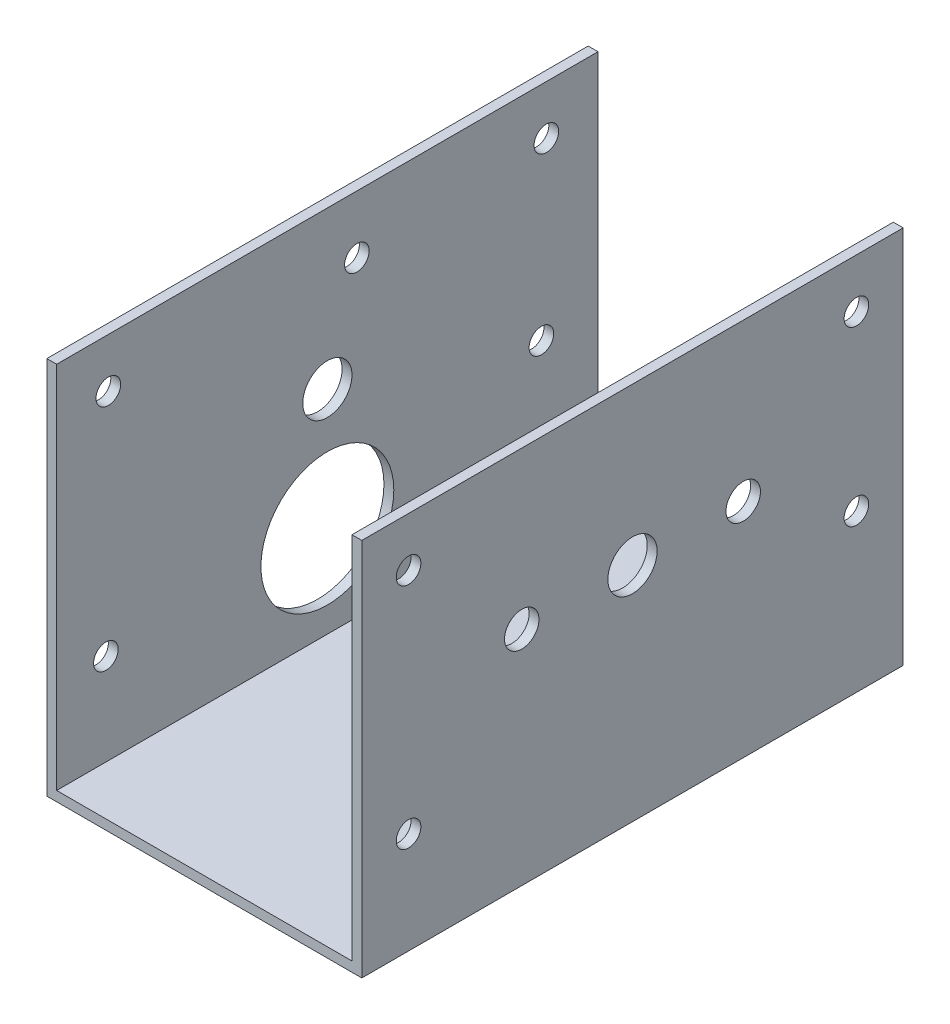
from build123d import *

# Parameters (mm, degrees)
ESBO_O1_W                  = 60
ESBO_O1_H                  = 110
ESBO_O1_R                  = 25
RESSALTO_EXTRUS_O1_DEPTH   = 2
ESBO_O2_W                  = 110
ESBO_O2_H                  = 77
RESSALTO_EXTRUS_O2_DEPTH   = 2
ESBO_O5_R                  = 13.5
ESBO_O5_R_2                = 1
CORTE_EXTRUS_O3_DEPTH      = 10
ESBO_O6_R                  = 2.5
CORTE_EXTRUS_O4_DEPTH      = 10
ESBO_O8_R                  = 5
CORTE_EXTRUS_O7_DEPTH      = 115.236596588
CORTE_EXTRUS_O7_DEPTH_BACK = 115.236596588
ESBO_O9_R                  = 2.5
CORTE_EXTRUS_O8_DEPTH      = 10
ESBO_O12_R                 = 2.5
CORTE_EXTRUS_O9_DEPTH      = 10
CORTE_EXTRUS_O10_REACH     = 116.237
ESBO_O13_R                 = 2.5
ESBO_O15_R                 = 3.5
CORTE_EXTRUS_O11_DEPTH     = 10
CUT_EXTRUDE1_REACH         = 116.237
SKETCH1_R                  = 2.5


with BuildPart() as part:
    # Esboço1 → Ressalto-extrusão1 (new body)
    with BuildSketch(Plane(origin=(0, 0, 0), x_dir=(1, 0, 0), z_dir=(0, 1, 0))):
        Rectangle(ESBO_O1_W, ESBO_O1_H)
        Circle(ESBO_O1_R, mode=Mode.SUBTRACT)
        Circle(ESBO_O1_R)
    extrude(amount=RESSALTO_EXTRUS_O1_DEPTH)

    # Esboço2 → Ressalto-extrusão2 (add)
    with BuildSketch(Plane.ZY.offset(30)):
        with Locations((0, 38.5)):
            Rectangle(ESBO_O2_W, ESBO_O2_H)
    ressalto_extrus_o2 = extrude(amount=RESSALTO_EXTRUS_O2_DEPTH)

    # Espelhar1: Ressalto-extrusão2 across plane
    add(ressalto_extrus_o2.mirror(Plane(origin=(0, 0, 0), x_dir=(0, 0, 1), z_dir=(1, 0, 0))))

    # Esboço5 → Corte-extrusão3 (cut)
    with BuildSketch(Plane(origin=(-30, 0, 0), x_dir=(0, 0, -1), z_dir=(1, 0, 0))):
        with Locations((0, 20.625)):
            Circle(ESBO_O5_R)
        with Locations((0, 20.625)):
            Circle(ESBO_O5_R_2, mode=Mode.SUBTRACT)
        with Locations((0, 20.625)):
            Circle(ESBO_O5_R_2)
    extrude(amount=-CORTE_EXTRUS_O3_DEPTH, mode=Mode.SUBTRACT)

    # Esboço6 → Corte-extrusão4 (cut)
    with BuildSketch(Plane.ZY.offset(32)):
        with Locations((45, 20.625)):
            Circle(ESBO_O6_R)
        with Locations((-6, 65.225)):
            Circle(ESBO_O6_R)
        with Locations((-43.5, 31.925)):
            Circle(ESBO_O6_R)
    extrude(amount=-CORTE_EXTRUS_O4_DEPTH, mode=Mode.SUBTRACT)

    # Esboço8 → Corte-extrusão7 (cut, two sides)
    with BuildSketch(Plane.ZY.offset(32)) as corte_extrus_o7_sk:
        with Locations((0, 45.125)):
            Circle(ESBO_O8_R)
    extrude(amount=CORTE_EXTRUS_O7_DEPTH, mode=Mode.SUBTRACT)
    extrude(corte_extrus_o7_sk.sketch, amount=-CORTE_EXTRUS_O7_DEPTH_BACK, mode=Mode.SUBTRACT)

    # Esboço9 → Corte-extrusão8 (cut)
    with BuildSketch(Plane(origin=(0, 2, 0), x_dir=(1, 0, 0), z_dir=(0, 1, 0))):
        with Locations(Location((-8.838834765, 8.838834765, 0), (0, 0, 270))):
            Circle(ESBO_O9_R)
        with Locations(Location((-8.838834765, -8.838834765, 0), (0, 0, 270))):
            Circle(ESBO_O9_R)
        with Locations(Location((8.838834765, 8.838834765, 0), (0, 0, 270))):
            Circle(ESBO_O9_R)
        with Locations(Location((8.838834765, -8.838834765, 0), (0, 0, 270))):
            Circle(ESBO_O9_R)
    extrude(amount=-CORTE_EXTRUS_O8_DEPTH, mode=Mode.SUBTRACT)

    # Esboço12 → Corte-extrusão9 (cut)
    with BuildSketch(Plane(origin=(32, 0, 0), x_dir=(0, 0, -1), z_dir=(1, 0, 0))):
        with Locations((45.5, 31.925)):
            Circle(ESBO_O12_R)
        with Locations((-45.5, 20.625)):
            Circle(ESBO_O12_R)
    extrude(amount=-CORTE_EXTRUS_O9_DEPTH, mode=Mode.SUBTRACT)

    # Esboço13 → Corte-extrusão10 (cut, up to next)
    with BuildSketch(Plane.ZY.offset(32), mode=Mode.PRIVATE) as corte_extrus_o10_sk1:
        with Locations((-44.5, 67)):
            Circle(ESBO_O13_R)
    corte_extrus_o10_tool1 = extrude(corte_extrus_o10_sk1.sketch, amount=-CORTE_EXTRUS_O10_REACH, mode=Mode.PRIVATE) & part.part
    # Esboço13 → Corte-extrusão10 (cut, up to next)
    with BuildSketch(Plane.ZY.offset(32), mode=Mode.PRIVATE) as corte_extrus_o10_sk2:
        with Locations(Location((44.5, 67, 0), (0, 0, 180))):
            Circle(ESBO_O13_R)
    corte_extrus_o10_tool2 = extrude(corte_extrus_o10_sk2.sketch, amount=-CORTE_EXTRUS_O10_REACH, mode=Mode.PRIVATE) & part.part
    add(corte_extrus_o10_tool1.solids().sort_by_distance((-32, 67, -44.5))[0], mode=Mode.SUBTRACT)
    add(corte_extrus_o10_tool2.solids().sort_by_distance((-32, 67, 44.5))[0], mode=Mode.SUBTRACT)

    # Esboço15 → Corte-extrusão11 (cut)
    with BuildSketch(Plane(origin=(32, 0, 0), x_dir=(0, 0, -1), z_dir=(1, 0, 0))):
        with Locations((-22.5, 45.125)):
            Circle(ESBO_O15_R)
        with Locations((22.5, 45.125)):
            Circle(ESBO_O15_R)
    extrude(amount=-CORTE_EXTRUS_O11_DEPTH, mode=Mode.SUBTRACT)

    # Sketch1 → Cut-Extrude1 (cut, up to next)
    with BuildSketch(Plane(origin=(32, 0, 0), x_dir=(0, 0, -1), z_dir=(1, 0, 0)), mode=Mode.PRIVATE) as cut_extrude1_sk1:
        with Locations((45.5, 67)):
            Circle(SKETCH1_R)
    cut_extrude1_tool1 = extrude(cut_extrude1_sk1.sketch, amount=-CUT_EXTRUDE1_REACH, mode=Mode.PRIVATE) & part.part
    # Sketch1 → Cut-Extrude1 (cut, up to next)
    with BuildSketch(Plane(origin=(32, 0, 0), x_dir=(0, 0, -1), z_dir=(1, 0, 0)), mode=Mode.PRIVATE) as cut_extrude1_sk2:
        with Locations(Location((-45.5, 67, 0), (0, 0, 180))):
            Circle(SKETCH1_R)
    cut_extrude1_tool2 = extrude(cut_extrude1_sk2.sketch, amount=-CUT_EXTRUDE1_REACH, mode=Mode.PRIVATE) & part.part
    add(cut_extrude1_tool1.solids().sort_by_distance((32, 67, -45.5))[0], mode=Mode.SUBTRACT)
    add(cut_extrude1_tool2.solids().sort_by_distance((32, 67, 45.5))[0], mode=Mode.SUBTRACT)


solid = part.part
